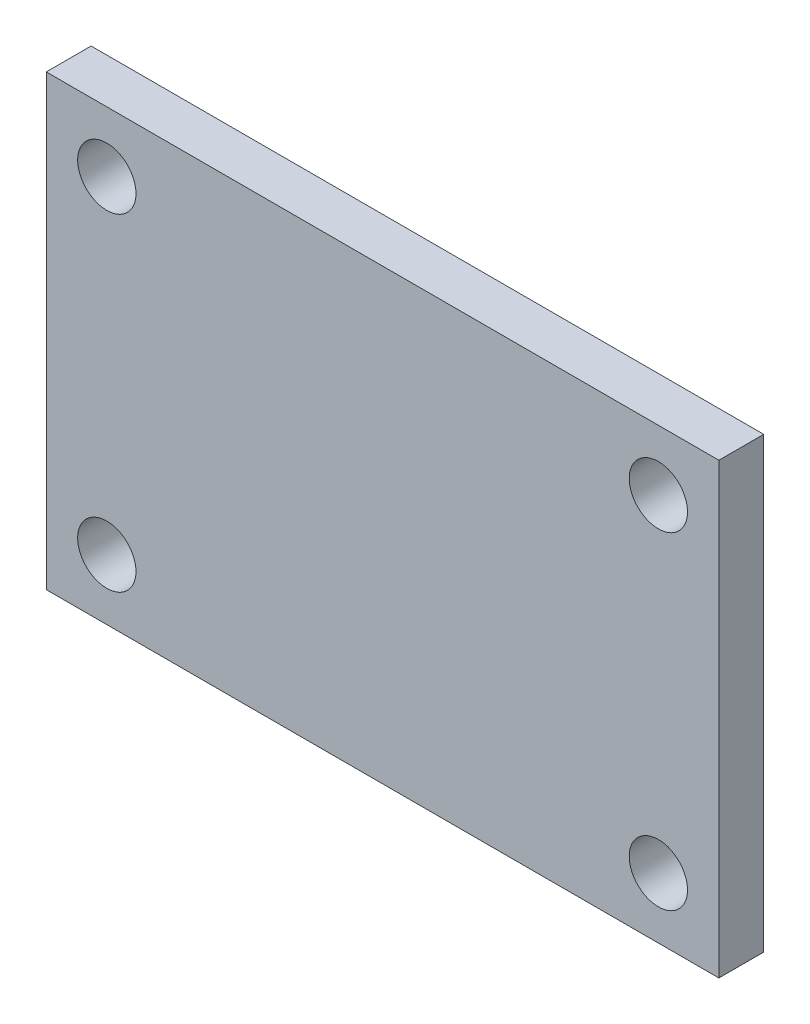
from build123d import *

# Parameters (mm, degrees)
PLAT_W                      = 100
PLAT_H                      = 10
EL_MENT_M_CANO_SOUD_1_DEPTH = 150
D_GAGEMENT_M121_D           = 13


with BuildPart() as part:
    # plat → Elément mécano-soudé1 (new body)
    with BuildSketch(Plane.YZ):
        Rectangle(PLAT_W, PLAT_H)
    extrude(amount=EL_MENT_M_CANO_SOUD_1_DEPTH)

    # Dégagement M121 (through all)
    with Locations(Plane.XY.offset(5)):
        with Locations((13.5, 36.5), (136.5, 36.5), (136.5, -36.5), (13.5, -36.5)):
            Hole(D_GAGEMENT_M121_D / 2)


solid = part.part
